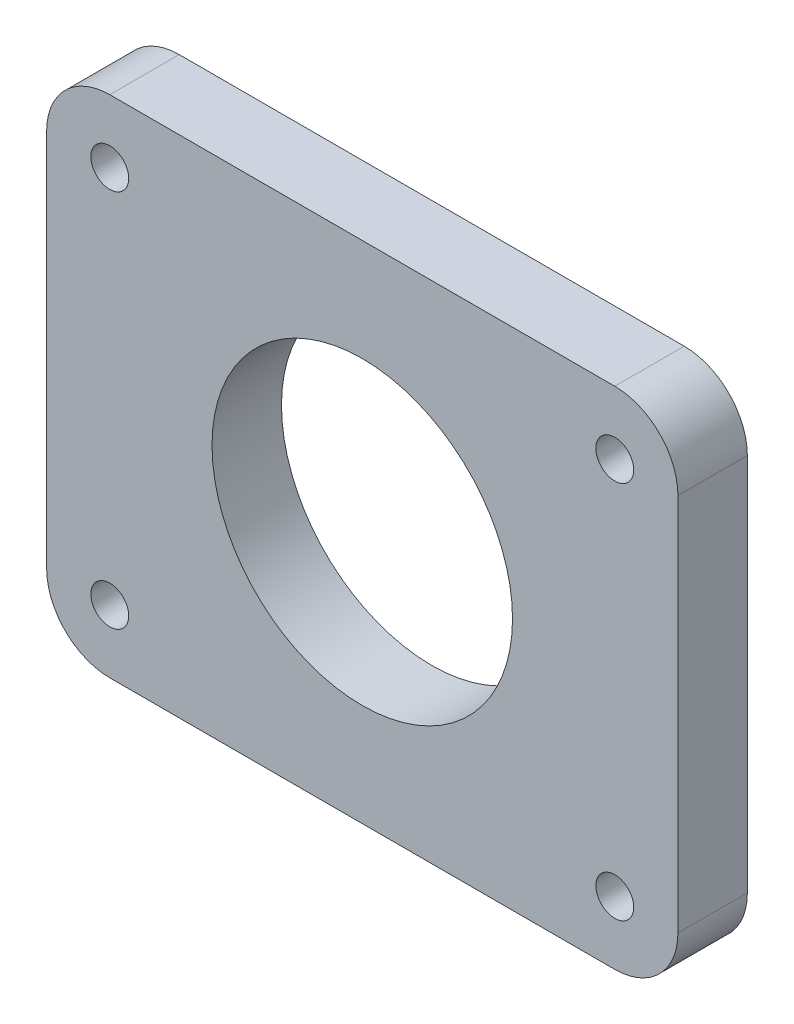
from build123d import *

# Parameters (mm, degrees)
CROQUIS1_R              = 1.5
CROQUIS1_R_2            = 11.9
SALIENTE_EXTRUIR1_DEPTH = 5.5


with BuildPart() as part:
    # Croquis1 → Saliente-Extruir1 (new body)
    with BuildSketch(Plane.XY):
        with BuildLine():
            Line((-20, 20), (20, 20))
            ThreePointArc((20, 20), (23.535533906, 18.535533906), (25, 15))
            Line((25, 15), (25, -15))
            ThreePointArc((25, -15), (23.535533906, -18.535533906), (20, -20))
            Line((20, -20), (-20, -20))
            ThreePointArc((-20, -20), (-23.535533906, -18.535533906), (-25, -15))
            Line((-25, -15), (-25, 15))
            ThreePointArc((-25, 15), (-23.535533906, 18.535533906), (-20, 20))
        make_face()
        with Locations((-20, 15)):
            Circle(CROQUIS1_R, mode=Mode.SUBTRACT)
        Circle(CROQUIS1_R_2, mode=Mode.SUBTRACT)
        with Locations((-20, -15)):
            Circle(CROQUIS1_R, mode=Mode.SUBTRACT)
        with Locations((20, -15)):
            Circle(CROQUIS1_R, mode=Mode.SUBTRACT)
        with Locations((20, 15)):
            Circle(CROQUIS1_R, mode=Mode.SUBTRACT)
    extrude(amount=SALIENTE_EXTRUIR1_DEPTH)


solid = part.part
